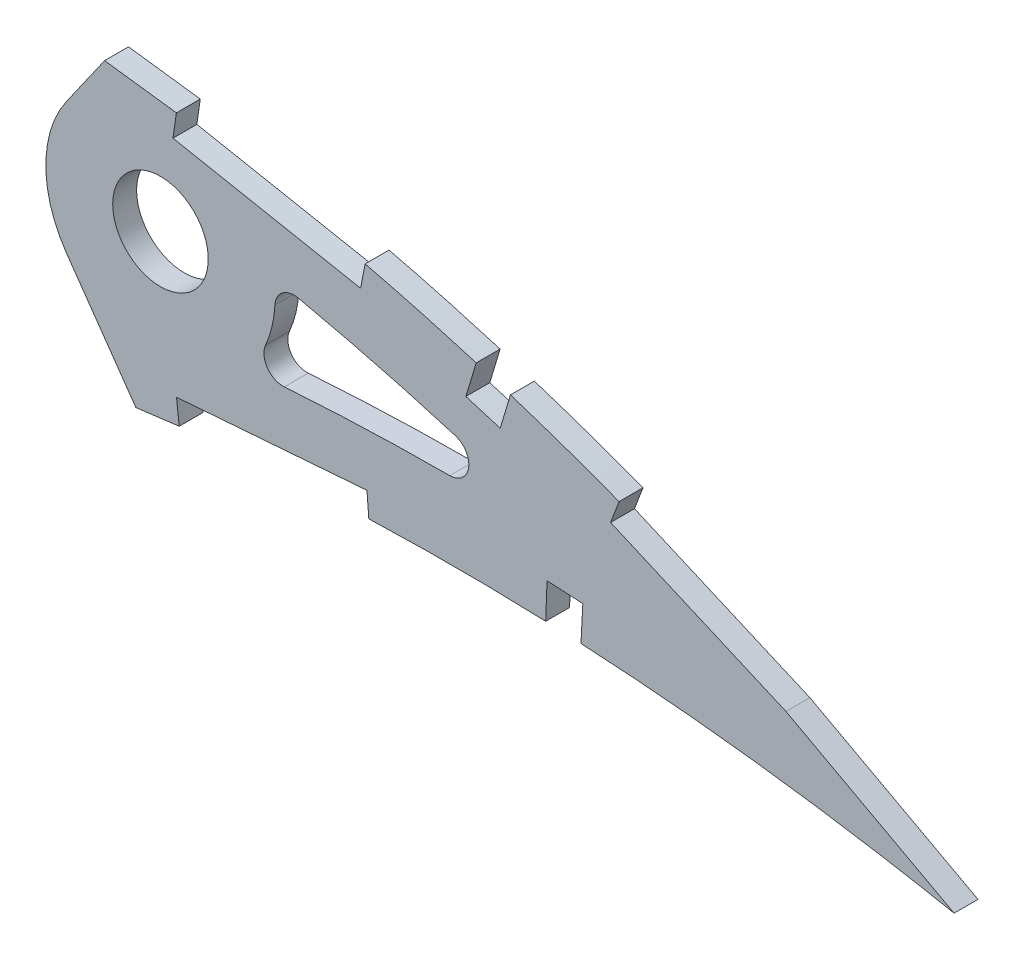
from build123d import *

# Parameters (mm, degrees)
BOSS_EXTRUDE1_DEPTH = 3.175
SKETCH3_R           = 6.35
CUT_EXTRUDE2_DEPTH  = 7.62
CUT_EXTRUDE3_DEPTH  = 391.201801695
CUT_EXTRUDE4_DEPTH  = 390.459249771
FILLET1_R           = 2.54


with BuildPart() as part:
    # Sketch1 → Boss-Extrude1 (new body)
    with BuildSketch(Plane.XY):
        with BuildLine():
            Line((383.459719795, -0.598570683), (387.151098381, -1.385981683))
            Line((387.151098381, -1.385981683), (383.938576586, 0.598570683))
            add(Edge.make_bspline(
                [(383.938576586, 0.598570683), (383.909164402, 0.616740215), (383.791629853, 0.689347806), (383.526803342, 0.851788775), (383.085812234, 1.122342517), (382.46846306, 1.499129399), (381.675235414, 1.981149322), (380.705730092, 2.565026812), (379.560552258, 3.248864764), (378.239979352, 4.02942936), (376.744146546, 4.903065392), (375.073623444, 5.866233811), (373.228555337, 6.913481558), (371.209656947, 8.040529653), (369.017620878, 9.242017712), (366.652862008, 10.5125194), (364.116227136, 11.845572217), (361.408689747, 13.235442203), (358.530743662, 14.674454529), (355.483745734, 16.156620323), (352.268711027, 17.674549225), (348.886737002, 19.220143157), (345.339766501, 20.787101279), (341.62878015, 22.365681942), (337.755892849, 23.949045726), (333.722753433, 25.528181676), (329.531749722, 27.095897536), (325.184498663, 28.642037582), (320.684250026, 30.159844956), (316.03318694, 31.639459621), (311.234635387, 33.072845765), (306.291383411, 34.45071), (301.207551835, 35.76598594), (295.986364862, 37.009095199), (290.632247735, 38.171716814), (285.149456354, 39.246851106), (279.542589067, 40.223764407), (273.827182957, 41.101695037), (268.095197614, 41.831984573), (262.375005403, 42.548231339), (256.663331957, 43.221079634), (250.881849899, 43.865424929), (245.036121341, 44.477639467), (239.131944816, 45.055808842), (233.175297421, 45.597437688), (227.172369204, 46.100937725), (221.12896887, 46.563455864), (215.051468851, 46.984279591), (208.945877574, 47.359709224), (202.818698224, 47.689463037), (196.676150699, 47.971241104), (190.524627328, 48.20310193), (184.370660154, 48.383645908), (178.220637202, 48.511143259), (172.081217377, 48.584792389), (165.95878665, 48.602580967), (159.860000816, 48.564190717), (153.791246295, 48.468303513), (147.759185686, 48.313606629), (141.770214134, 48.099811437), (135.830807778, 47.827010592), (129.947469668, 47.492919603), (124.126582163, 47.099667535), (118.374627308, 46.64560247), (112.697924861, 46.1306036), (107.102424066, 45.556817635), (101.594354639, 44.922683996), (96.179619551, 44.23000695), (90.864141437, 43.480144639), (85.653884398, 42.672688505), (80.554429795, 41.809970933), (75.571281385, 40.892874577), (70.709711341, 39.924088059), (65.975012599, 38.903864189), (61.372197101, 37.835263284), (56.906048373, 36.72014713), (52.581367423, 35.560557176), (48.402538226, 34.359275924), (44.373786491, 33.11902871), (40.499808771, 31.84117832), (36.783532955, 30.530569775), (33.229524089, 29.188133497), (29.840504666, 27.818005118), (26.620446377, 26.422055375), (23.571754691, 25.004539962), (20.697880073, 23.567072571), (18.000870717, 22.113680535), (15.483434196, 20.646592482), (13.147993867, 19.168533315), (10.995531238, 17.683252327), (9.029014018, 16.191681681), (7.249117676, 14.697590602), (5.656968684, 13.203254087), (4.254842735, 11.709701653), (3.042689485, 10.219563342), (2.022097407, 8.734019375), (1.193243635, 7.254475378), (0.55800286, 5.78200614), (0.115745172, 4.317439731), (-0.126343705, 2.862937809), (-0.186601112, 1.417334332), (-0.062107432, 0.471738862), (0, 0)],
                knots=[0, 0, 0, 0, 0.00025409, 0.001015374, 0.002283359, 0.004056577, 0.006330982, 0.009105274, 0.01237449, 0.016134024, 0.020379661, 0.025105976, 0.030306237, 0.035972206, 0.042099523, 0.048678064, 0.055701664, 0.063160184, 0.071045824, 0.079349827, 0.08806291, 0.097175757, 0.106678112, 0.116561573, 0.126814276, 0.1374283, 0.148393618, 0.15969976, 0.171338126, 0.183297699, 0.195569604, 0.208143556, 0.221011594, 0.234161831, 0.247587451, 0.261276823, 0.27522271, 0.289414144, 0.3037712, 0.317689227, 0.331784111, 0.346039677, 0.36044387, 0.374982721, 0.389640455, 0.404403317, 0.419256601, 0.43418675, 0.449177265, 0.464214782, 0.479284009, 0.49436974, 0.509457833, 0.524532346, 0.53957932, 0.554582984, 0.569529546, 0.584403417, 0.599190992, 0.613876838, 0.628447475, 0.642888675, 0.657186054, 0.671325546, 0.685294014, 0.699078148, 0.712665095, 0.726042645, 0.739197713, 0.752117587, 0.764792042, 0.777208152, 0.789355685, 0.80122396, 0.812803686, 0.824082909, 0.835054602, 0.845709571, 0.856037853, 0.866033835, 0.875688843, 0.884997719, 0.893953426, 0.902552897, 0.910789386, 0.918660734, 0.926166253, 0.933302626, 0.94007122, 0.94647478, 0.952517526, 0.958204819, 0.963546652, 0.9685566, 0.973249913, 0.977651041, 0.981787043, 0.985694226, 0.989415109, 0.993001157, 0.996508416, 1, 1, 1, 1], degree=3))
            add(Edge.make_bspline(
                [(0, 0), (0.098594067, -0.465429756), (0.296235321, -1.398428295), (0.833200827, -2.741559621), (1.543312041, -4.032697891), (2.441472641, -5.268413507), (3.521710628, -6.448368806), (4.781640288, -7.573790979), (6.220025893, -8.64407503), (7.834984953, -9.658733762), (9.624171422, -10.618844355), (11.585574313, -11.523809795), (13.717405168, -12.373347376), (16.017341357, -13.166321391), (18.482571114, -13.903939589), (21.110750633, -14.584404413), (23.898891402, -15.208666937), (26.844311765, -15.775133676), (29.943802121, -16.284380139), (33.194142548, -16.736121271), (36.59199678, -17.130639725), (40.134031288, -17.46710754), (43.816742631, -17.74624851), (47.636460203, -17.96824782), (51.589476278, -18.133809384), (55.672004278, -18.242303834), (59.880045838, -18.295422597), (64.209798061, -18.293963098), (68.657025429, -18.237535039), (73.217928944, -18.129255696), (77.888131918, -17.96843911), (82.663418096, -17.757031491), (87.53948011, -17.497160264), (92.511944666, -17.189706447), (97.576435823, -16.836032634), (102.728556211, -16.438975174), (107.9636256, -15.999524359), (113.277078315, -15.52024171), (118.664210326, -15.003526584), (124.120367239, -14.4510143), (129.640733027, -13.865303885), (135.220390799, -13.248293384), (140.854593983, -12.603274503), (146.538195749, -11.931414237), (152.266389991, -11.236548635), (158.033787934, -10.52000534), (163.835566864, -9.784544171), (169.666508639, -9.033628137), (175.521154495, -8.267171513), (181.394580274, -7.490635069), (187.28112183, -6.703379195), (193.175655329, -5.90945278), (199.072724256, -5.111323575), (204.966584816, -4.309237241), (210.852056119, -3.506517822), (216.72367834, -2.705368887), (222.575700149, -1.905863728), (228.402826975, -1.111976133), (234.199191111, -0.323609112), (239.959447702, 0.457639018), (245.678076832, 1.229436212), (251.34968319, 1.990808513), (256.968416226, 2.741274105), (262.528623029, 3.481114832), (267.941468501, 4.187874758), (273.192808754, 4.89918891), (278.300339848, 5.482308989), (283.344275668, 5.980022849), (288.329855672, 6.388079628), (293.25109327, 6.712349854), (298.102349784, 6.95515067), (302.877843519, 7.119871856), (307.571542288, 7.211400107), (312.17758361, 7.232058132), (316.689680406, 7.188433969), (321.101964205, 7.084044048), (325.408277014, 6.923573954), (329.602611012, 6.712437706), (333.679008651, 6.45639092), (337.631349997, 6.159210609), (341.4541277, 5.827834534), (345.141443703, 5.46711367), (348.687636023, 5.081169316), (352.087530269, 4.678088588), (355.335684636, 4.260525247), (358.42721331, 3.835341496), (361.357139876, 3.406846029), (364.120823945, 2.98050952), (366.713923524, 2.560399127), (369.132249836, 2.152090859), (371.372014685, 1.759399564), (373.429331453, 1.386160167), (375.301346074, 1.037081953), (376.984361404, 0.713898906), (378.476126466, 0.421937235), (379.773867448, 0.162485176), (380.875681878, -0.060801967), (381.779645661, -0.247042835), (382.484385883, -0.393180216), (382.98851051, -0.499447588), (383.291474212, -0.56268208), (383.426084821, -0.591395979), (383.459719795, -0.598570683)],
                knots=[0, 0, 0, 0, 0.003638255, 0.007293231, 0.011028136, 0.014901081, 0.018963272, 0.023258475, 0.027820626, 0.032679082, 0.03785316, 0.043361875, 0.049214679, 0.055422346, 0.061988786, 0.068918036, 0.076211157, 0.083868392, 0.091887411, 0.100265912, 0.108999867, 0.11808453, 0.127514843, 0.13728527, 0.147387918, 0.157816481, 0.168563473, 0.179619128, 0.190977373, 0.202626974, 0.214560478, 0.226767249, 0.239236417, 0.251959004, 0.264923895, 0.278119703, 0.291536035, 0.30516028, 0.318980685, 0.332985499, 0.347162791, 0.361498603, 0.375980747, 0.390597192, 0.405332594, 0.420174823, 0.435109533, 0.450124276, 0.465203068, 0.480333154, 0.495500583, 0.510689775, 0.525887335, 0.541078314, 0.556247233, 0.571381785, 0.586466041, 0.601484516, 0.616424329, 0.631269423, 0.646006524, 0.660620684, 0.675098187, 0.689422858, 0.703581825, 0.716907564, 0.730009274, 0.742952128, 0.755725558, 0.768319952, 0.780724338, 0.792926529, 0.804916041, 0.816679084, 0.828203524, 0.839474901, 0.850481359, 0.861207697, 0.871639326, 0.881763414, 0.891563605, 0.901027365, 0.910138977, 0.918883977, 0.927249278, 0.935221104, 0.942784739, 0.949928188, 0.956638465, 0.962904204, 0.968712288, 0.974054485, 0.978918432, 0.983297218, 0.987180246, 0.990560675, 0.993433358, 0.995790626, 0.997629588, 0.998945816, 0.999736593, 1, 1, 1, 1], degree=3))
        make_face()
    extrude(amount=BOSS_EXTRUDE1_DEPTH)

    # Sketch3 → Cut-Extrude2 (cut)
    with BuildSketch(Plane(origin=(0, 0, 0), x_dir=(-1, 0, 0), z_dir=(0, 0, -1))):
        with Locations((-272.41988512, 26.255421435)):
            Circle(SKETCH3_R)
    extrude(amount=-CUT_EXTRUDE2_DEPTH, mode=Mode.SUBTRACT)

    # Sketch4 → Cut-Extrude3 (cut, through all)
    with BuildSketch(Plane.XY.offset(3.175)):
        with BuildLine():
            ThreePointArc((258.636275142, 32.756936333), (259.238482127, 33.904487726), (259.936007965, 34.996726325))
            Line((259.936007965, 34.996726325), (264.993177896, 42.219113481))
            add(Edge.make_bspline(
                [(264.993177896, 42.219113481), (264.128267545, 42.326681207), (261.359885786, 42.667814769), (256.663331957, 43.221079634), (250.881849899, 43.865424929), (245.036121341, 44.477639467), (239.131944816, 45.055808842), (233.175297421, 45.597437688), (227.172369204, 46.100937725), (221.12896887, 46.563455864), (215.051468851, 46.984279591), (208.945877574, 47.359709224), (202.818698224, 47.689463037), (196.676150699, 47.971241104), (190.524627328, 48.20310193), (184.370660154, 48.383645908), (178.220637202, 48.511143259), (172.081217377, 48.584792389), (165.95878665, 48.602580967), (159.860000816, 48.564190717), (153.503835436, 48.463762379), (149.182034244, 48.349894835), (146.883754049, 48.276045968)],
                knots=[0.311283457, 0.311283457, 0.311283457, 0.311283457, 0.317689227, 0.331784111, 0.346039677, 0.36044387, 0.374982721, 0.389640455, 0.404403317, 0.419256601, 0.43418675, 0.449177265, 0.464214782, 0.479284009, 0.49436974, 0.509457833, 0.524532346, 0.53957932, 0.554582984, 0.569529546, 0.584403417, 0.601303588, 0.601303588, 0.601303588, 0.601303588], degree=3))
            add(Edge.make_bspline(
                [(146.883754049, 48.276045968), (145.173898454, 48.221104496), (141.483069263, 48.086622684), (135.830807778, 47.827010592), (129.947469668, 47.492919603), (124.126582163, 47.099667535), (118.374627308, 46.64560247), (112.697924861, 46.1306036), (107.102424066, 45.556817635), (101.594354639, 44.922683996), (96.179619551, 44.23000695), (90.864141437, 43.480144639), (85.653884398, 42.672688505), (80.554429795, 41.809970933), (75.571281385, 40.892874577), (70.709711341, 39.924088059), (65.975012599, 38.903864189), (61.372197101, 37.835263284), (56.906048373, 36.72014713), (52.581367423, 35.560557176), (48.402538226, 34.359275924), (44.373786491, 33.11902871), (40.499808771, 31.84117832), (36.783532955, 30.530569775), (33.229524089, 29.188133497), (29.840504666, 27.818005118), (26.620446377, 26.422055375), (23.571754691, 25.004539962), (20.697880073, 23.567072571), (18.000870717, 22.113680535), (15.483434196, 20.646592482), (13.147993867, 19.168533315), (10.995531238, 17.683252327), (9.029014018, 16.191681681), (7.249117676, 14.697590602), (5.656968684, 13.203254087), (4.254842735, 11.709701653), (3.042689485, 10.219563342), (2.022097407, 8.734019375), (1.193243635, 7.254475378), (0.55800286, 5.78200614), (0.115745172, 4.317439731), (-0.126343705, 2.862937809), (-0.186601112, 1.417334332), (-0.062107432, 0.471738862), (0, 0)],
                knots=[0.601303588, 0.601303588, 0.601303588, 0.601303588, 0.613876838, 0.628447475, 0.642888675, 0.657186054, 0.671325546, 0.685294014, 0.699078148, 0.712665095, 0.726042645, 0.739197713, 0.752117587, 0.764792042, 0.777208152, 0.789355685, 0.80122396, 0.812803686, 0.824082909, 0.835054602, 0.845709571, 0.856037853, 0.866033835, 0.875688843, 0.884997719, 0.893953426, 0.902552897, 0.910789386, 0.918660734, 0.926166253, 0.933302626, 0.94007122, 0.94647478, 0.952517526, 0.958204819, 0.963546652, 0.9685566, 0.973249913, 0.977651041, 0.981787043, 0.985694226, 0.989415109, 0.993001157, 0.996508416, 1, 1, 1, 1], degree=3))
            add(Edge.make_bspline(
                [(0, 0), (0.098594067, -0.465429756), (0.296235321, -1.398428295), (0.833200827, -2.741559621), (1.543312041, -4.032697891), (2.441472641, -5.268413507), (3.521710628, -6.448368806), (4.781640288, -7.573790979), (6.220025893, -8.64407503), (7.834984953, -9.658733762), (9.624171422, -10.618844355), (11.585574313, -11.523809795), (13.717405168, -12.373347376), (16.017341357, -13.166321391), (18.482571114, -13.903939589), (21.110750633, -14.584404413), (23.898891402, -15.208666937), (26.844311765, -15.775133676), (29.943802121, -16.284380139), (33.194142548, -16.736121271), (36.59199678, -17.130639725), (40.134031288, -17.46710754), (43.816742631, -17.74624851), (47.636460203, -17.96824782), (51.589476278, -18.133809384), (55.672004278, -18.242303834), (59.880045838, -18.295422597), (64.209798061, -18.293963098), (68.657025429, -18.237535039), (73.217928944, -18.129255696), (77.888131918, -17.96843911), (82.663418096, -17.757031491), (87.53948011, -17.497160264), (92.511944666, -17.189706447), (97.576435823, -16.836032634), (102.728556211, -16.438975174), (107.9636256, -15.999524359), (113.277078315, -15.52024171), (118.664210326, -15.003526584), (124.120367239, -14.4510143), (129.640733027, -13.865303885), (135.220390799, -13.248293384), (140.854593983, -12.603274503), (146.538195749, -11.931414237), (152.266389991, -11.236548635), (157.244201726, -10.618103774), (160.312006991, -10.230799494), (161.45711025, -10.085478827)],
                knots=[0, 0, 0, 0, 0.003638255, 0.007293231, 0.011028136, 0.014901081, 0.018963272, 0.023258475, 0.027820626, 0.032679082, 0.03785316, 0.043361875, 0.049214679, 0.055422346, 0.061988786, 0.068918036, 0.076211157, 0.083868392, 0.091887411, 0.100265912, 0.108999867, 0.11808453, 0.127514843, 0.13728527, 0.147387918, 0.157816481, 0.168563473, 0.179619128, 0.190977373, 0.202626974, 0.214560478, 0.226767249, 0.239236417, 0.251959004, 0.264923895, 0.278119703, 0.291536035, 0.30516028, 0.318980685, 0.332985499, 0.347162791, 0.361498603, 0.375980747, 0.390597192, 0.405332594, 0.420174823, 0.429015566, 0.429015566, 0.429015566, 0.429015566], degree=3))
            add(Edge.make_bspline(
                [(161.45711025, -10.085478827), (162.246435442, -9.985308592), (164.980400668, -9.63711103), (169.666508639, -9.033628137), (175.521154495, -8.267171513), (181.394580274, -7.490635069), (187.28112183, -6.703379195), (193.175655329, -5.90945278), (199.072724256, -5.111323575), (204.966584816, -4.309237241), (210.852056119, -3.506517822), (216.72367834, -2.705368887), (222.575700149, -1.905863728), (228.402826975, -1.111976133), (234.199191111, -0.323609112), (239.959447702, 0.457639018), (245.678076832, 1.229436212), (251.34968319, 1.990808513), (256.968416226, 2.741274105), (262.528623029, 3.481114832), (266.583838647, 4.010607851), (268.783690281, 4.304486241), (269.151142409, 4.353540657)],
                knots=[0.429015566, 0.429015566, 0.429015566, 0.429015566, 0.435109533, 0.450124276, 0.465203068, 0.480333154, 0.495500583, 0.510689775, 0.525887335, 0.541078314, 0.556247233, 0.571381785, 0.586466041, 0.601484516, 0.616424329, 0.631269423, 0.646006524, 0.660620684, 0.675098187, 0.689422858, 0.703581825, 0.706421091, 0.706421091, 0.706421091, 0.706421091], degree=3))
            Line((269.151142409, 4.353540657), (262.583654743, 13.732885077))
            Line((262.583654743, 13.732885077), (259.936007965, 17.514116545))
            ThreePointArc((259.936007965, 17.514116545), (257.234987727, 24.960627569), (258.636275142, 32.756936333))
        make_face()
        with BuildLine():
            add(Edge.make_bspline(
                [(327.549181489, 16.98603205), (326.824956948, 17.255063713), (321.470908621, 19.218235632), (311.379208006, 22.563584273), (298.702483107, 26.00149194), (290.712241282, 27.773311637), (287.505134836, 28.421718046)],
                knots=[0.144436945, 0.144436945, 0.144436945, 0.144436945, 0.150325897, 0.187907371, 0.225488845, 0.250466936, 0.250466936, 0.250466936, 0.250466936], degree=3))
            ThreePointArc((287.505134836, 28.421718046), (287.621148319, 27.341329886), (287.65988512, 26.255421435))
            ThreePointArc((287.65988512, 26.255421435), (286.68429662, 20.890333871), (283.882435702, 16.212138398))
            add(Edge.make_bspline(
                [(283.882435702, 16.212138398), (284.380055625, 16.254830388), (287.276976077, 16.496512621), (292.572797624, 16.8640824), (302.188464838, 17.315929241), (313.854957689, 17.470710505), (323.107860186, 17.20273134), (327.549181489, 16.98603205)],
                knots=[0.746492785, 0.746492785, 0.746492785, 0.746492785, 0.75019431, 0.768037574, 0.785880837, 0.821567364, 0.854595374, 0.854595374, 0.854595374, 0.854595374], degree=3))
        make_face()
    extrude(amount=-CUT_EXTRUDE3_DEPTH, mode=Mode.SUBTRACT)

    # Sketch5 → Cut-Extrude4 (cut, through all)
    with BuildSketch(Plane.XY.offset(3.175)):
        with BuildLine():
            add(Edge.make_bspline(
                [(299.624398141, 36.13644563), (298.424501349, 36.426858934), (295.444247173, 37.126813532), (290.632247735, 38.171716814), (285.149456354, 39.246851106), (279.770936215, 40.18397831), (276.216351623, 40.734415073), (274.534483108, 40.97601376)],
                knots=[0.225088548, 0.225088548, 0.225088548, 0.225088548, 0.234161831, 0.247587451, 0.261276823, 0.27522271, 0.287710696, 0.287710696, 0.287710696, 0.287710696], degree=3))
            Line((274.534483108, 40.97601376), (274.083031687, 37.833273457))
            Line((274.083031687, 37.833273457), (299.022613693, 33.018997879))
            Line((299.022613693, 33.018997879), (299.624398141, 36.13644563))
        make_face()
        with BuildLine():
            add(Edge.make_bspline(
                [(318.940828887, 30.710119476), (317.985349351, 31.016233704), (316.470853017, 31.492443021), (314.952360948, 31.955704373), (314.392994499, 32.124427397)],
                knots=[0.175923769, 0.175923769, 0.175923769, 0.175923769, 0.183297699, 0.187591729, 0.187591729, 0.187591729, 0.187591729], degree=3))
            Line((314.392994499, 32.124427397), (313.017673371, 27.564833331))
            Line((313.017673371, 27.564833331), (317.577267437, 26.189512203))
            Line((317.577267437, 26.189512203), (318.940828887, 30.710119476))
        make_face()
        with BuildLine():
            add(Edge.make_bspline(
                [(356.947809213, 15.442648045), (356.476147426, 15.671834195), (354.93622837, 16.415122177), (352.268711027, 17.674549225), (348.886737002, 19.220143157), (345.339766501, 20.787101279), (341.62878015, 22.365681942), (337.755892849, 23.949045726), (334.985526139, 25.033755481), (333.509547657, 25.597744153), (333.382575061, 25.646158956)],
                knots=[0.075495727, 0.075495727, 0.075495727, 0.075495727, 0.079349827, 0.08806291, 0.097175757, 0.106678112, 0.116561573, 0.126814276, 0.1374283, 0.13842703, 0.13842703, 0.13842703, 0.13842703], degree=3))
            Line((333.382575061, 25.646158956), (332.25138626, 22.679504798))
            Line((332.25138626, 22.679504798), (355.560182174, 12.586931637))
            Line((355.560182174, 12.586931637), (356.947809213, 15.442648045))
        make_face()
        with BuildLine():
            add(Edge.make_bspline(
                [(379.538106568, 3.260948486), (379.124721487, 3.506470471), (378.213445898, 4.044926133), (376.744146546, 4.903065392), (375.073623444, 5.866233811), (373.228555337, 6.913481558), (371.209656947, 8.040529653), (369.017620878, 9.242017712), (366.652862008, 10.5125194), (364.116227136, 11.845572217), (361.408689747, 13.235442203), (358.999781827, 14.439929044), (357.492384938, 15.178032133), (356.947809213, 15.442648045)],
                knots=[0.012600324, 0.012600324, 0.012600324, 0.012600324, 0.016134024, 0.020379661, 0.025105976, 0.030306237, 0.035972206, 0.042099523, 0.048678064, 0.055701664, 0.063160184, 0.071045824, 0.075495727, 0.075495727, 0.075495727, 0.075495727], degree=3))
            Line((356.947809213, 15.442648045), (355.560182174, 12.586931637))
            Line((355.560182174, 12.586931637), (377.916781847, 0.531125937))
            Line((377.916781847, 0.531125937), (379.538106568, 3.260948486))
        make_face()
        with BuildLine():
            Line((274.545291907, 8.243392136), (274.917358333, 5.090268039))
            add(Edge.make_bspline(
                [(274.917358333, 5.090268039), (276.051562825, 5.224103371), (278.866167352, 5.53814241), (283.344275668, 5.980022849), (288.329855672, 6.388079628), (293.25109327, 6.712349854), (297.172305481, 6.908602829), (299.45218138, 6.997517141), (300.113766812, 7.021215382)],
                knots=[0.721262157, 0.721262157, 0.721262157, 0.721262157, 0.730009274, 0.742952128, 0.755725558, 0.768319952, 0.780724338, 0.785794655, 0.785794655, 0.785794655, 0.785794655], degree=3))
            Line((300.113766812, 7.021215382), (299.870827414, 10.18690732))
            Line((299.870827414, 10.18690732), (274.545291907, 8.243392136))
        make_face()
        with BuildLine():
            add(Edge.make_bspline(
                [(383.938576586, 0.598570683), (383.909164402, 0.616740215), (383.791629853, 0.689347806), (383.526803342, 0.851788775), (383.085812234, 1.122342517), (382.46846306, 1.499129399), (381.675235414, 1.981149322), (380.705730092, 2.565026812), (379.973354152, 3.002361912), (379.564525487, 3.245257485), (379.538106568, 3.260948486)],
                knots=[0, 0, 0, 0, 0.00025409, 0.001015374, 0.002283359, 0.004056577, 0.006330982, 0.009105274, 0.01237449, 0.012600324, 0.012600324, 0.012600324, 0.012600324], degree=3))
            Line((379.538106568, 3.260948486), (377.916781847, 0.531125937))
            add(Edge.make_bspline(
                [(377.916781847, 0.531125937), (378.124660337, 0.490345398), (378.765544528, 0.364075063), (379.773867448, 0.162485176), (380.875681878, -0.060801967), (381.779645661, -0.247042835), (382.484385883, -0.393180216), (382.98851051, -0.499447588), (383.291474212, -0.56268208), (383.426084821, -0.591395979), (383.459719795, -0.598570683)],
                knots=[0.985557748, 0.985557748, 0.985557748, 0.985557748, 0.987180246, 0.990560675, 0.993433358, 0.995790626, 0.997629588, 0.998945816, 0.999736593, 1, 1, 1, 1], degree=3))
            Line((383.459719795, -0.598570683), (387.151098381, -1.385981683))
            Line((387.151098381, -1.385981683), (383.938576586, 0.598570683))
        make_face()
        with BuildLine():
            Line((323.807185741, 11.746480623), (323.625046444, 6.987464809))
            add(Edge.make_bspline(
                [(323.625046444, 6.987464809), (324.231568894, 6.964251695), (325.795034786, 6.900013286), (327.358005414, 6.824525333), (328.314492602, 6.774166864)],
                knots=[0.845832607, 0.845832607, 0.845832607, 0.845832607, 0.850481359, 0.857817238, 0.857817238, 0.857817238, 0.857817238], degree=3))
            Line((328.314492602, 6.774166864), (328.563098706, 11.496084697))
            Line((328.563098706, 11.496084697), (323.807185741, 11.746480623))
        make_face()
    extrude(amount=-CUT_EXTRUDE4_DEPTH, mode=Mode.SUBTRACT)

    # Fillet1
    fillet1_edges = [part.edges().sort_by_distance(p)[0] for p in [
        (327.549181489, 16.98603205, 1.5875),
        (287.505134836, 28.421718046, 1.5875),
        (283.882435702, 16.212138398, 1.5875),
    ]]
    fillet(fillet1_edges, radius=FILLET1_R)


solid = part.part
